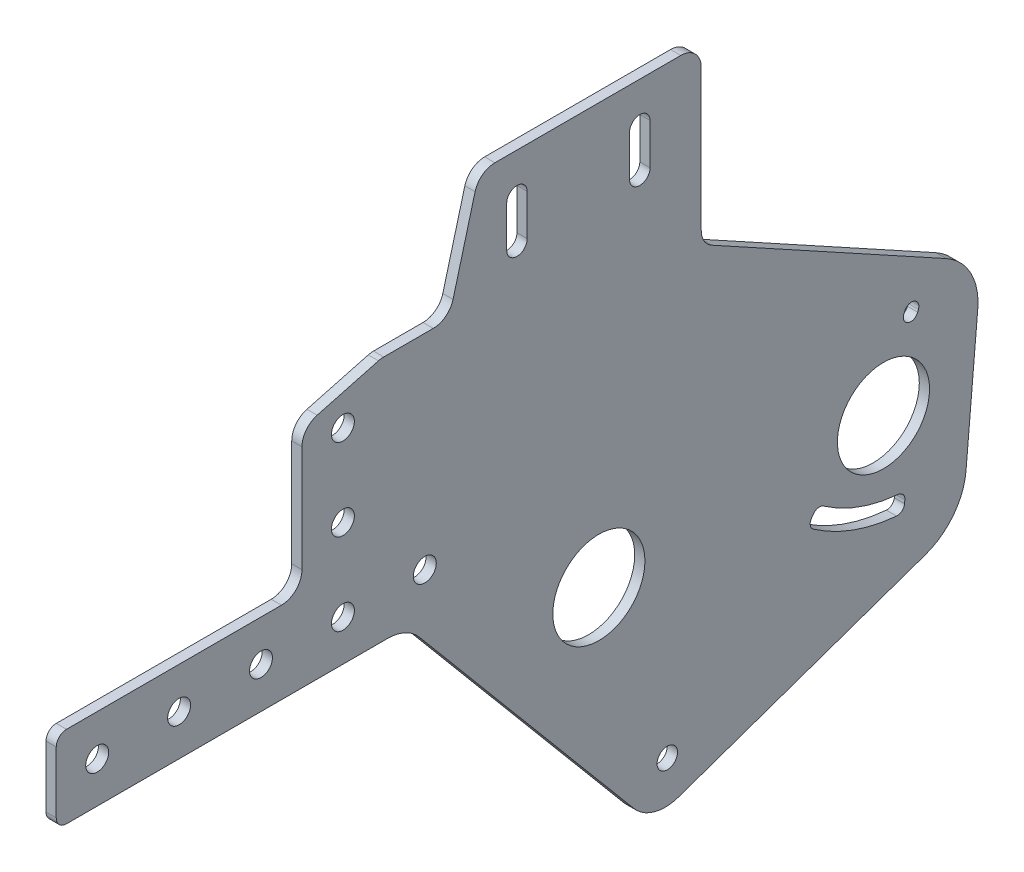
from build123d import *

# Parameters (mm, degrees)
SKETCH2_R           = 14.2875
SKETCH2_R_2         = 3.556
SKETCH2_R_3         = 3.175
BOSS_EXTRUDE1_DEPTH = 3.175


with BuildPart() as part:
    # Sketch2 → Boss-Extrude1 (new body)
    with BuildSketch(Plane(origin=(0, 0, 0), x_dir=(0, 0, -1), z_dir=(1, 0, 0))):
        with BuildLine():
            Line((-165.1, 19.05), (-65.425970741, 19.05))
            ThreePointArc((-65.425970741, 19.05), (-60.058718817, 17.860108895), (-55.697206313, 14.513402643))
            Line((-55.697206313, 14.513402643), (10.854621695, -64.799977479))
            ThreePointArc((10.854621695, -64.799977479), (17.220460091, -68.883236769), (24.778864428, -68.623566193))
            Line((24.778864428, -68.623566193), (101.178891774, -41.883356934))
            ThreePointArc((101.178891774, -41.883356934), (109.926930654, -35.593169628), (113.863183314, -25.563186798))
            Line((113.863183314, -25.563186798), (117.509534259, 16.114795214))
            ThreePointArc((117.509534259, 16.114795214), (115.335280515, 26.750250711), (107.704738864, 34.471333996))
            Line((107.704738864, 34.471333996), (35.042428799, 74.391177223))
            ThreePointArc((35.042428799, 74.391177223), (32.634742589, 76.723403199), (31.75, 79.956584517))
            Line((31.75, 79.956584517), (31.75, 123.825))
            ThreePointArc((31.75, 123.825), (29.890128061, 128.315128061), (25.4, 130.175))
            Line((25.4, 130.175), (-32.251185784, 130.175))
            ThreePointArc((-32.251185784, 130.175), (-36.116820858, 128.862793711), (-38.384814781, 125.468500936))
            Line((-38.384814781, 125.468500936), (-45.22073508, 99.956499064))
            ThreePointArc((-45.22073508, 99.956499064), (-47.488729003, 96.562206289), (-51.354364077, 95.25))
            Line((-51.354364077, 95.25), (-66.704490653, 95.25))
            ThreePointArc((-66.704490653, 95.25), (-67.533331973, 95.19567487), (-68.347991589, 95.033628997))
            Line((-68.347991589, 95.033628997), (-87.368500936, 89.937098878))
            ThreePointArc((-87.368500936, 89.937098878), (-90.762793711, 87.669104955), (-92.075, 83.803469881))
            Line((-92.075, 83.803469881), (-92.075, 50.8))
            ThreePointArc((-92.075, 50.8), (-93.934871939, 46.309871939), (-98.425, 44.45))
            Line((-98.425, 44.45), (-165.1, 44.45))
            ThreePointArc((-165.1, 44.45), (-167.34506403, 43.52006403), (-168.275, 41.275))
            Line((-168.275, 41.275), (-168.275, 22.225))
            ThreePointArc((-168.275, 22.225), (-167.34506403, 19.97993597), (-165.1, 19.05))
        make_face()
        Circle(SKETCH2_R, mode=Mode.SUBTRACT)
        with Locations((-53.975, 31.75)):
            Circle(SKETCH2_R_2, mode=Mode.SUBTRACT)
        with Locations((-79.375, 31.75)):
            Circle(SKETCH2_R_2, mode=Mode.SUBTRACT)
        with Locations((-104.775, 31.75)):
            Circle(SKETCH2_R_2, mode=Mode.SUBTRACT)
        with Locations((-130.175, 31.75)):
            Circle(SKETCH2_R_2, mode=Mode.SUBTRACT)
        with Locations((-155.575, 31.75)):
            Circle(SKETCH2_R_2, mode=Mode.SUBTRACT)
        with Locations((88.260023092, 2.022732411)):
            Circle(SKETCH2_R, mode=Mode.SUBTRACT)
        with Locations((-79.375, 57.15)):
            Circle(SKETCH2_R_2, mode=Mode.SUBTRACT)
        with Locations((-79.375, 82.55)):
            Circle(SKETCH2_R_2, mode=Mode.SUBTRACT)
        with Locations((21.222889041, -56.412747143)):
            Circle(SKETCH2_R_3, mode=Mode.SUBTRACT)
        with BuildLine():
            Line((94.576884308, 26.061982823), (94.799197401, 26.672783027))
            ThreePointArc((94.799197401, 26.672783027), (97.72919278, 28.03906231), (99.095472064, 25.109066932))
            Line((99.095472064, 25.109066932), (98.87315897, 24.498266728))
            ThreePointArc((98.87315897, 24.498266728), (95.943163592, 23.131987445), (94.576884308, 26.061982823))
        make_face(mode=Mode.SUBTRACT)
        with BuildLine():
            Line((66.519823852, -13.57854466), (65.937070193, -14.410803137))
            ThreePointArc((65.937070193, -14.410803137), (65.558381242, -16.118958605), (66.498456032, -17.594580444))
            ThreePointArc((66.498456032, -17.594580444), (78.790853404, -23.993597488), (92.320584973, -26.993066764))
            ThreePointArc((92.320584973, -26.993066764), (93.989235477, -26.466943281), (94.797124081, -24.915003712))
            Line((94.797124081, -24.915003712), (94.885674315, -23.902869899))
            ThreePointArc((94.885674315, -23.902869899), (94.359550833, -22.234219395), (92.807611263, -21.426330791))
            ThreePointArc((92.807611263, -21.426330791), (80.702061965, -18.742595123), (69.703601159, -13.01715882))
            ThreePointArc((69.703601159, -13.01715882), (67.995445691, -12.63846987), (66.519823852, -13.57854466))
        make_face(mode=Mode.SUBTRACT)
        with BuildLine():
            Line((-22.225, 117.475), (-22.225, 104.775))
            ThreePointArc((-22.225, 104.775), (-25.4, 101.6), (-28.575, 104.775))
            Line((-28.575, 104.775), (-28.575, 117.475))
            ThreePointArc((-28.575, 117.475), (-25.4, 120.65), (-22.225, 117.475))
        make_face(mode=Mode.SUBTRACT)
        with BuildLine():
            Line((15.875, 117.475), (15.875, 104.775))
            ThreePointArc((15.875, 104.775), (12.7, 101.6), (9.525, 104.775))
            Line((9.525, 104.775), (9.525, 117.475))
            ThreePointArc((9.525, 117.475), (12.7, 120.65), (15.875, 117.475))
        make_face(mode=Mode.SUBTRACT)
    extrude(amount=BOSS_EXTRUDE1_DEPTH)


solid = part.part
